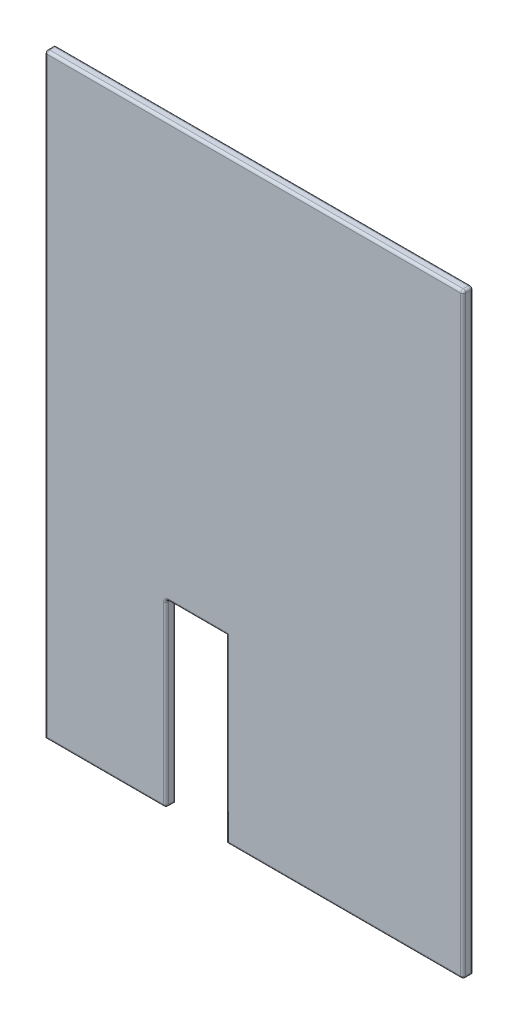
from build123d import *

# Parameters (mm, degrees)
BOSS_EXTRUDE1_DEPTH = 20
FILLET1_R           = 5


with BuildPart() as part:
    # Sketch1 → Boss-Extrude1 (new body)
    with BuildSketch(Plane.XY):
        Polygon((-175.5, -595), (-175.5, -235), (-55.5, -235), (-55.5, -595), (417.5, -595), (417.5, 595), (-417.5, 595), (-417.5, -595), align=None)
    extrude(amount=BOSS_EXTRUDE1_DEPTH)

    # Fillet1
    fillet1_edges = [part.edges().sort_by_distance(p)[0] for p in [
        (0, 595, 0),
        (417.5, 0, 0),
        (0, 595, 20),
        (-175.5, -235, 10),
        (-175.5, -595, 10),
        (-417.5, 595, 10),
        (417.5, 595, 10),
        (417.5, -595, 10),
        (-417.5, 0, 20),
        (-296.5, -595, 20),
        (-175.5, -415, 20),
        (-115.5, -235, 20),
        (-55.5, -415, 20),
        (181, -595, 20),
        (417.5, 0, 20),
        (-115.5, -235, 0),
        (-175.5, -415, 0),
    ]]
    fillet(fillet1_edges, radius=FILLET1_R)


solid = part.part
